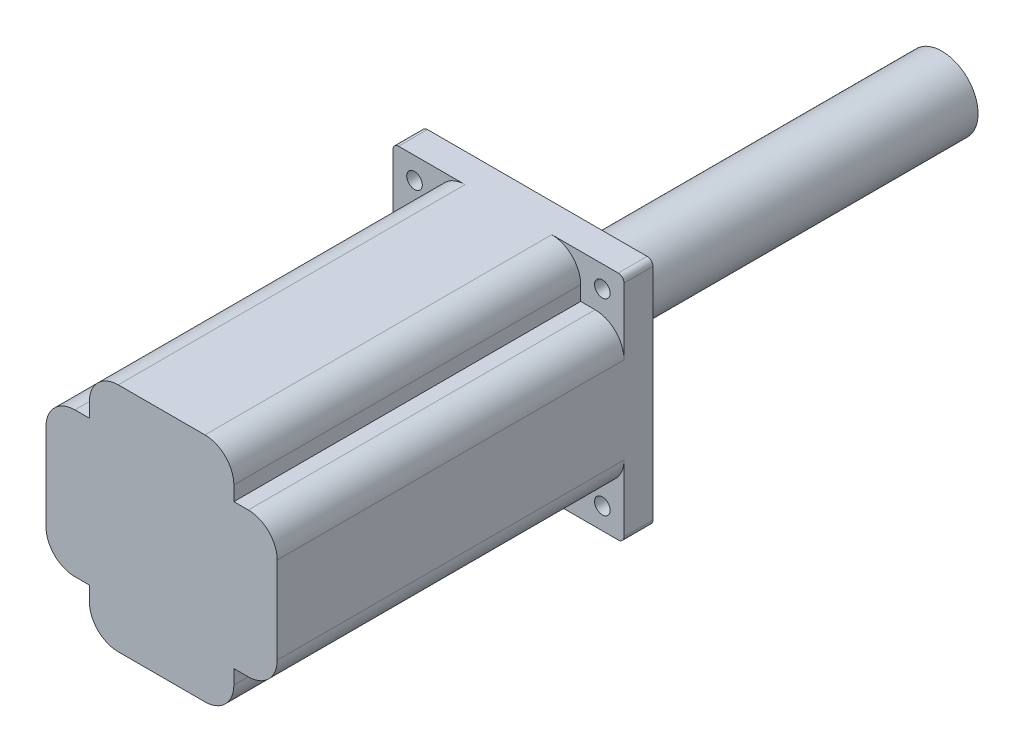
from build123d import *

# Parameters (mm, degrees)
SKETCH_1_W          = 80
SKETCH_1_H          = 80
SKETCH_1_R          = 2.7
EXTRUDE_1_DEPTH     = 130
SKETCH_2_R          = 12.5
EXTRUDE_2_DEPTH     = 140
SKETCH_3_W          = 15
SKETCH_3_H          = 15
CUT_EXTRUDE_1_DEPTH = 120
FILLET_1_R          = 2
FILLET_3_R          = 10


with BuildPart() as part:
    # 草图1 → 凸台-拉伸1 (new body)
    with BuildSketch(Plane.XY):
        Rectangle(SKETCH_1_W, SKETCH_1_H)
        with Locations((-32.5, 32.5)):
            Circle(SKETCH_1_R, mode=Mode.SUBTRACT)
        with Locations((32.5, 32.5)):
            Circle(SKETCH_1_R, mode=Mode.SUBTRACT)
        with Locations((32.5, -32.5)):
            Circle(SKETCH_1_R, mode=Mode.SUBTRACT)
        with Locations((-32.5, -32.5)):
            Circle(SKETCH_1_R, mode=Mode.SUBTRACT)
    extrude(amount=EXTRUDE_1_DEPTH)

    # 草图2 → 凸台-拉伸2 (add)
    with BuildSketch(Plane(origin=(0, 0, 0), x_dir=(-1, 0, 0), z_dir=(0, 0, -1))):
        Circle(SKETCH_2_R)
    extrude(amount=EXTRUDE_2_DEPTH)

    # 草图3 → 切除-拉伸1 (cut)
    with BuildSketch(Plane.XY.offset(130)):
        with Locations((-32.5, 32.5)):
            Rectangle(SKETCH_3_W, SKETCH_3_H)
        with Locations((32.5, 32.5)):
            Rectangle(SKETCH_3_W, SKETCH_3_H)
        with Locations((32.5, -32.5)):
            Rectangle(SKETCH_3_W, SKETCH_3_H)
        with Locations((-32.5, -32.5)):
            Rectangle(SKETCH_3_W, SKETCH_3_H)
    extrude(amount=-CUT_EXTRUDE_1_DEPTH, mode=Mode.SUBTRACT)

    # 圆角1
    fillet_1_edges = [part.edges().sort_by_distance(p)[0] for p in [
        (40, -40, 5),
        (-40, -40, 5),
        (-40, 40, 5),
        (40, 40, 5),
    ]]
    fillet(fillet_1_edges, radius=FILLET_1_R)

    # 圆角3
    fillet_3_edges = [part.edges().sort_by_distance(p)[0] for p in [
        (-25, -40, 70),
        (-40, -25, 70),
        (40, -25, 70),
        (25, -40, 70),
        (25, 40, 70),
        (40, 25, 70),
        (-40, 25, 70),
        (-25, 40, 70),
    ]]
    fillet(fillet_3_edges, radius=FILLET_3_R)


solid = part.part
